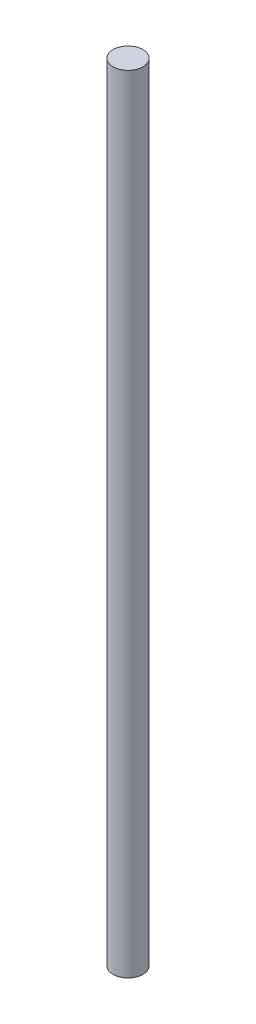
from build123d import *

# Parameters (mm, degrees)
SKETCH2_R           = 0.75
BOSS_EXTRUDE1_DEPTH = 39.5


with BuildPart() as part:
    # Sketch2 → Boss-Extrude1 (new body)
    with BuildSketch(Plane(origin=(0, 0, 0), x_dir=(1, 0, 0), z_dir=(0, 1, 0))):
        Circle(SKETCH2_R)
    extrude(amount=BOSS_EXTRUDE1_DEPTH)


solid = part.part
